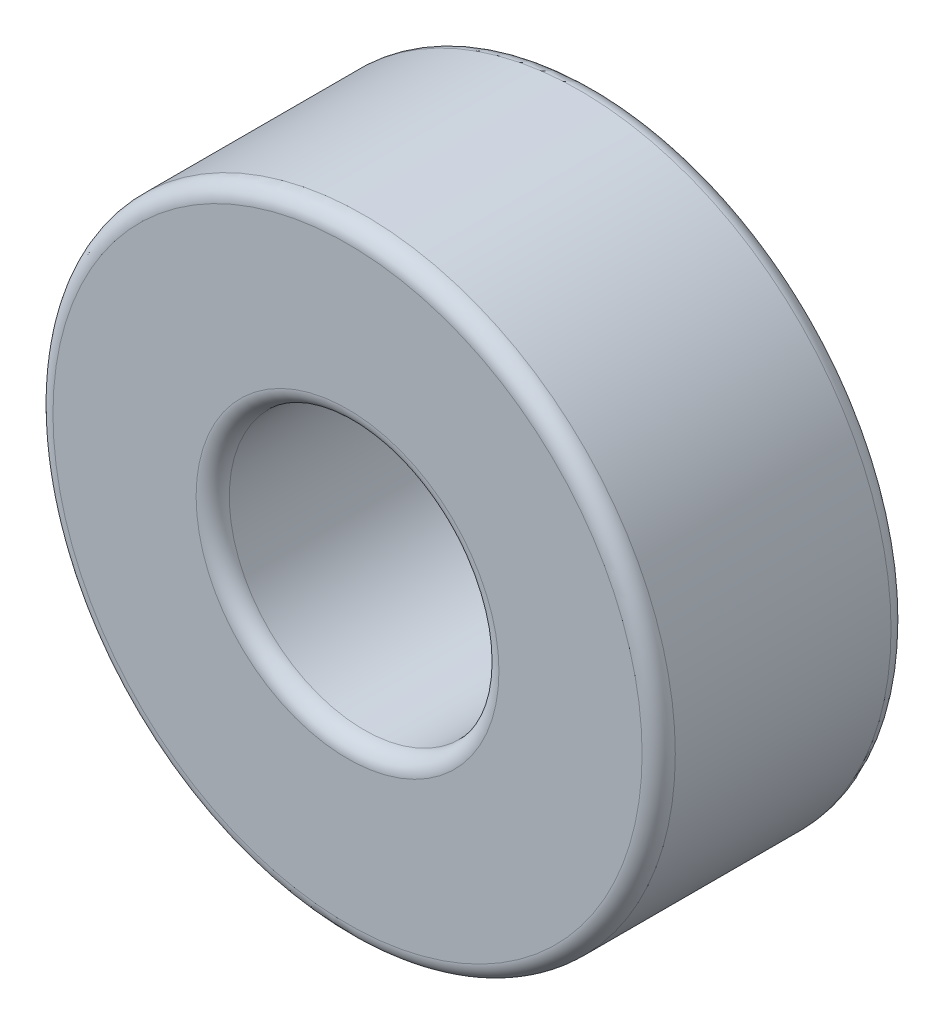
from build123d import *

# Parameters (mm, degrees)
SKETCH1_R           = 15
SKETCH1_R_2         = 6.5
BOSS_EXTRUDE1_DEPTH = 6
FILLET2_R           = 0.8


with BuildPart() as part:
    # Sketch1 → Boss-Extrude1 (new body, symmetric)
    with BuildSketch(Plane.XY):
        Circle(SKETCH1_R)
        Circle(SKETCH1_R_2, mode=Mode.SUBTRACT)
    extrude(amount=BOSS_EXTRUDE1_DEPTH, both=True)

    # Fillet2
    fillet2_edges = [part.edges().sort_by_distance(p)[0] for p in [
        (-15, 0, -6),
        (-15, 0, 6),
        (-6.5, 0, -6),
        (-6.5, 0, 6),
    ]]
    fillet(fillet2_edges, radius=FILLET2_R)


solid = part.part
